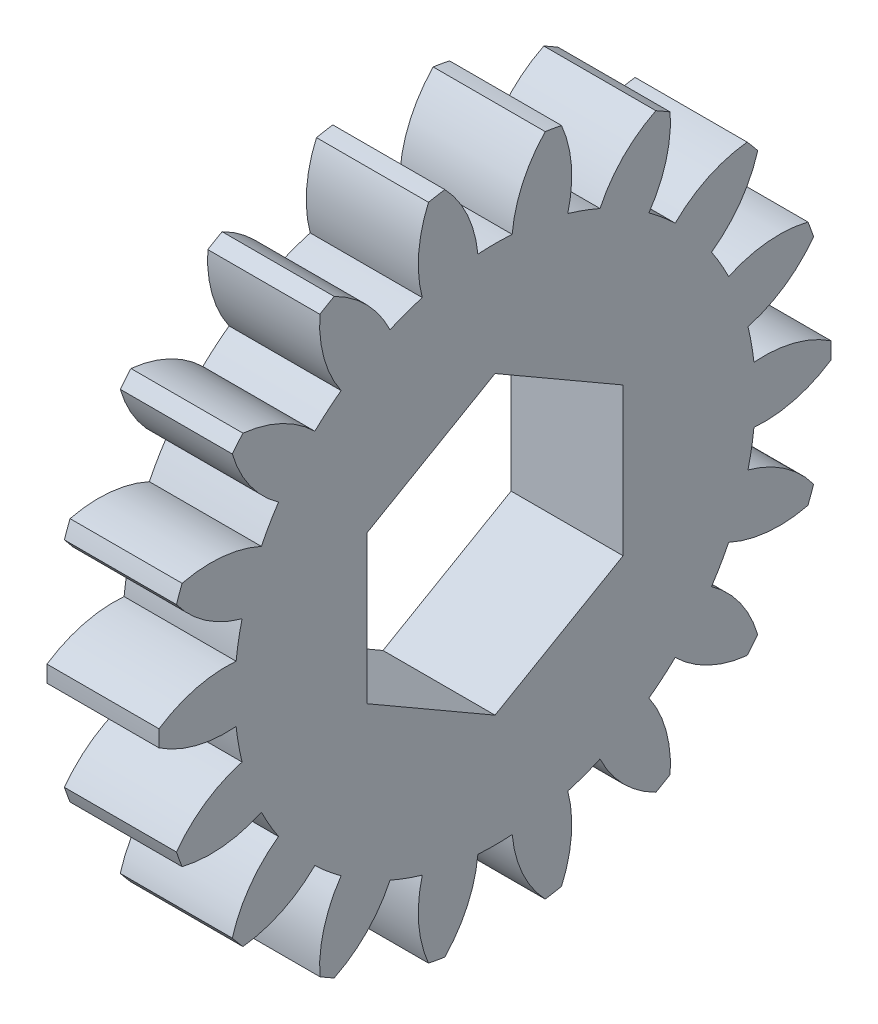
from build123d import *

# Parameters (mm, degrees)
BASPROSKE_W        = 3
BASPROSKE_H        = 9
TOOTHCUT_DEPTH     = 14.076696831
TEETHCUTS_COUNT    = 18
TEETHCUTS_ANGLE    = 340
CUT_EXTRUDE1_DEPTH = 14.007462246


with BuildPart() as part:
    # BasProSke → Base-Revolve (revolve)
    with BuildSketch(Plane(origin=(0, 0, 0), x_dir=(1, 0, 0), z_dir=(0, 1, 0)), mode=Mode.PRIVATE) as base_revolve_sk:
        with Locations((1.5, 4.5)):
            Rectangle(BASPROSKE_W, BASPROSKE_H)
    revolve(base_revolve_sk.sketch.rotate(Axis((-10, 0, 0), (1, 0, 0)), 180), axis=Axis((-10, 0, 0), (1, 0, 0)))

    # TooCutSke → ToothCut (cut, through all)
    with BuildSketch(Plane(origin=(0, 0, 0), x_dir=(0, 0, -1), z_dir=(1, 0, 0))):
        with BuildLine():
            ThreePointArc((0.45926649, 6.958861278), (0, 6.974), (-0.45926649, 6.958861278))
            ThreePointArc((-0.45926649, 6.958861278), (-0.743858876, 8.01799277), (-1.365479267, 8.921508366))
            ThreePointArc((-1.365479267, 8.921508366), (0, 9.0254), (1.365479267, 8.921508366))
            ThreePointArc((1.365479267, 8.921508366), (0.743858876, 8.01799277), (0.45926649, 6.958861278))
        make_face()
    toothcut = extrude(amount=TOOTHCUT_DEPTH, mode=Mode.SUBTRACT)

    # TeethCuts: ToothCut ×18 about axis
    teethcuts_axis = Axis((-10, 0, 0), (1, 0, 0))
    for i in range(1, TEETHCUTS_COUNT):
        add(toothcut.rotate(teethcuts_axis, i * TEETHCUTS_ANGLE / (TEETHCUTS_COUNT - 1)), mode=Mode.SUBTRACT)

    # Sketch1 → Cut-Extrude1 (cut, through all)
    with BuildSketch(Plane(origin=(3, 0, 0), x_dir=(0, 0, -1), z_dir=(1, 0, 0))):
        Polygon((0, 3.960622847), (-3.43, 1.980311423), (-3.43, -1.980311423), (0, -3.960622847), (3.43, -1.980311423), (3.43, 1.980311423), align=None)
    extrude(amount=-CUT_EXTRUDE1_DEPTH, mode=Mode.SUBTRACT)


solid = part.part
